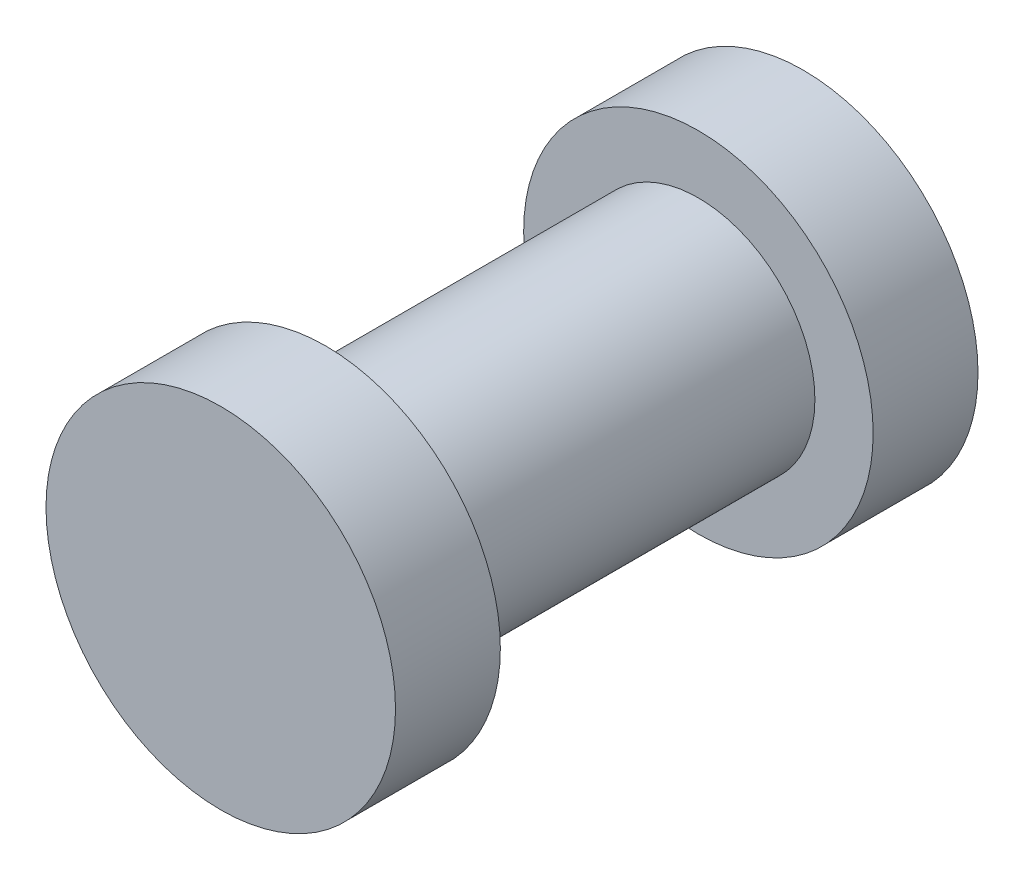
from build123d import *

# Parameters (mm, degrees)
SKETCH1_R           = 2
BOSS_EXTRUDE1_DEPTH = 5
SKETCH2_R           = 3
BOSS_EXTRUDE2_DEPTH = 1.8


with BuildPart() as part:
    # Sketch1 → Boss-Extrude1 (new body, symmetric)
    with BuildSketch(Plane.XY):
        Circle(SKETCH1_R)
    extrude(amount=BOSS_EXTRUDE1_DEPTH, both=True)

    # Sketch2 → Boss-Extrude2 (add)
    with BuildSketch(Plane.XY.offset(5)):
        Circle(SKETCH2_R)
    boss_extrude2 = extrude(amount=-BOSS_EXTRUDE2_DEPTH)

    # Mirror1: Boss-Extrude2 across plane
    add(boss_extrude2.mirror(Plane.XY))


solid = part.part
